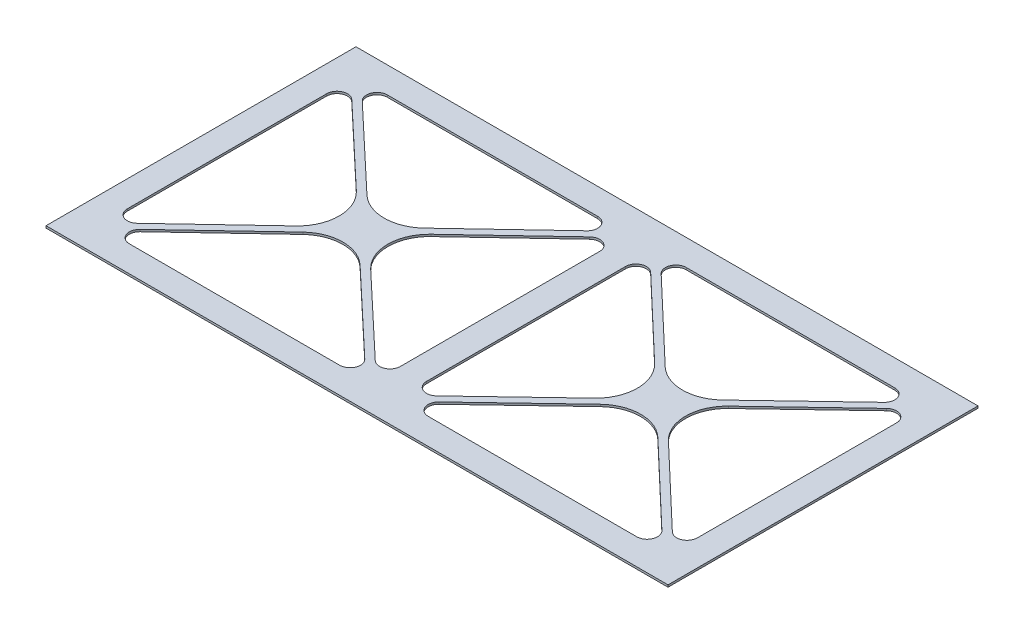
from build123d import *

# Parameters (mm, degrees)
SKETCH1_W           = 239.2
SKETCH1_H           = 119.2
BOSS_EXTRUDE1_DEPTH = 0.8
FILLET2_R           = 16
FILLET3_R           = 4


with BuildPart() as part:
    # Sketch1 → Boss-Extrude1 (new body)
    with BuildSketch(Plane(origin=(0, 0, 0), x_dir=(1, 0, 0), z_dir=(0, 1, 0))):
        with Locations((119.6, 59.6)):
            Rectangle(SKETCH1_W, SKETCH1_H)
        Polygon((10, 107.2), (60.440329218, 59.6), (10, 12), align=None, mode=Mode.SUBTRACT)
        Polygon((12, 109.2), (113, 109.2), (62.5, 61.54368932), align=None, mode=Mode.SUBTRACT)
        Polygon((12, 10), (113, 10), (62.5, 57.65631068), align=None, mode=Mode.SUBTRACT)
        Polygon((115, 107.2), (115, 12), (64.559670782, 59.6), align=None, mode=Mode.SUBTRACT)
        Polygon((127, 109.2), (227.2, 109.2), (177.1, 61.551076321), align=None, mode=Mode.SUBTRACT)
        Polygon((125, 107.2), (125, 12), (175.048559671, 59.6), align=None, mode=Mode.SUBTRACT)
        Polygon((127, 10), (227.2, 10), (177.1, 57.648923679), align=None, mode=Mode.SUBTRACT)
        Polygon((229.2, 107.2), (229.2, 12), (179.151440329, 59.6), align=None, mode=Mode.SUBTRACT)
    extrude(amount=BOSS_EXTRUDE1_DEPTH)

    # Fillet2
    fillet2_edges = [part.edges().sort_by_distance(p)[0] for p in [
        (62.5, 0.4, -61.54368932),
        (60.440329218, 0.4, -59.6),
        (175.048559671, 0.4, -59.6),
        (177.1, 0.4, -57.648923679),
        (177.1, 0.4, -61.551076321),
        (62.5, 0.4, -57.65631068),
        (64.559670782, 0.4, -59.6),
        (179.151440329, 0.4, -59.6),
    ]]
    fillet(fillet2_edges, radius=FILLET2_R)

    # Fillet3
    fillet3_edges = [part.edges().sort_by_distance(p)[0] for p in [
        (113, 0.4, -109.2),
        (12, 0.4, -109.2),
        (10, 0.4, -12),
        (10, 0.4, -107.2),
        (125, 0.4, -107.2),
        (125, 0.4, -12),
        (227.2, 0.4, -10),
        (127, 0.4, -10),
        (227.2, 0.4, -109.2),
        (127, 0.4, -109.2),
        (113, 0.4, -10),
        (12, 0.4, -10),
        (115, 0.4, -12),
        (115, 0.4, -107.2),
        (229.2, 0.4, -12),
        (229.2, 0.4, -107.2),
    ]]
    fillet(fillet3_edges, radius=FILLET3_R)


solid = part.part
